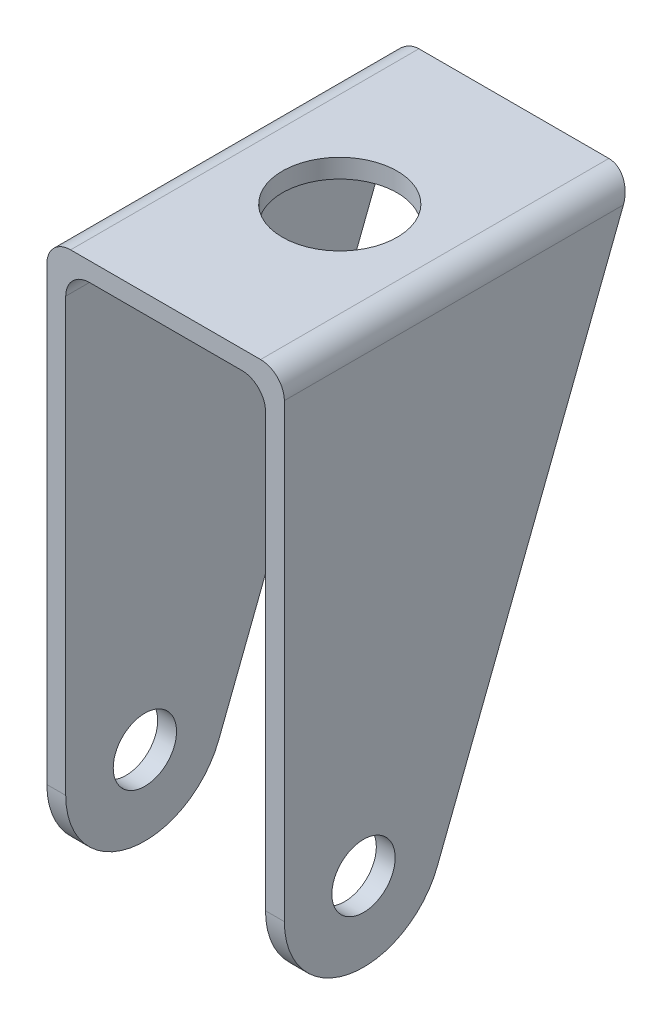
from build123d import *

# Parameters (mm, degrees)
CROQUIS1_W              = 30
CROQUIS1_H              = 44
CROQUIS1_R              = 7.25
SALIENTE_EXTRUIR1_DEPTH = 2.38
CROQUIS2_R              = 4
SALIENTE_EXTRUIR2_DEPTH = 2.38
CORTAR_EXTRUIR1_DEPTH   = 31
CROQUIS4_R              = 4
SALIENTE_EXTRUIR3_DEPTH = 2.38
REDONDEO1_R             = 3
REDONDEO2_R             = 3
REDONDEO3_R             = 3


with BuildPart() as part:
    # Croquis1 → Saliente-Extruir1 (new body)
    with BuildSketch(Plane(origin=(0, 0, 0), x_dir=(1, 0, 0), z_dir=(0, 1, 0))):
        Rectangle(CROQUIS1_W, CROQUIS1_H)
        Circle(CROQUIS1_R, mode=Mode.SUBTRACT)
    extrude(amount=-SALIENTE_EXTRUIR1_DEPTH)

    # Croquis2 → Saliente-Extruir2 (add)
    with BuildSketch(Plane(origin=(15, 0, 0), x_dir=(0, 0, -1), z_dir=(1, 0, 0))):
        with BuildLine():
            Line((-22, -60), (-22, 0))
            Line((-22, 0), (22, 0))
            Line((22, 0), (-2.676843343, -63.616455439))
            ThreePointArc((-2.676843343, -63.616455439), (-13.839624069, -69.8293328), (-22, -60))
        make_face()
        with Locations((-12, -60)):
            Circle(CROQUIS2_R, mode=Mode.SUBTRACT)
    extrude(amount=-SALIENTE_EXTRUIR2_DEPTH)

    # Croquis3 → Cortar-Extruir1 (cut, through all)
    with BuildSketch(Plane(origin=(15, 0, 0), x_dir=(0, 0, -1), z_dir=(1, 0, 0))):
        Polygon((22, 0), (21.076797241, -2.38), (22, -2.38), align=None)
    extrude(amount=-CORTAR_EXTRUIR1_DEPTH, mode=Mode.SUBTRACT)

    # Croquis4 → Saliente-Extruir3 (add)
    with BuildSketch(Plane.ZY.offset(15)):
        with BuildLine():
            Line((-22, 0), (2.676843343, -63.616455439))
            ThreePointArc((2.676843343, -63.616455439), (13.839624069, -69.8293328), (22, -60))
            Line((22, -60), (22, 0))
            Line((22, 0), (-22, 0))
        make_face()
        with Locations((12, -60)):
            Circle(CROQUIS4_R, mode=Mode.SUBTRACT)
    extrude(amount=-SALIENTE_EXTRUIR3_DEPTH)

    # Redondeo1
    redondeo1_edges = [part.edges().sort_by_distance(p)[0] for p in [
        (12.62, -2.38, 0.461601379),
    ]]
    fillet(redondeo1_edges, radius=REDONDEO1_R)

    # Redondeo2
    redondeo2_edges = [part.edges().sort_by_distance(p)[0] for p in [
        (-12.62, -2.38, 0.461601379),
    ]]
    fillet(redondeo2_edges, radius=REDONDEO2_R)

    # Redondeo3
    redondeo3_edges = [part.edges().sort_by_distance(p)[0] for p in [
        (-15, 0, 0),
        (15, 0, 0),
    ]]
    fillet(redondeo3_edges, radius=REDONDEO3_R)


solid = part.part
